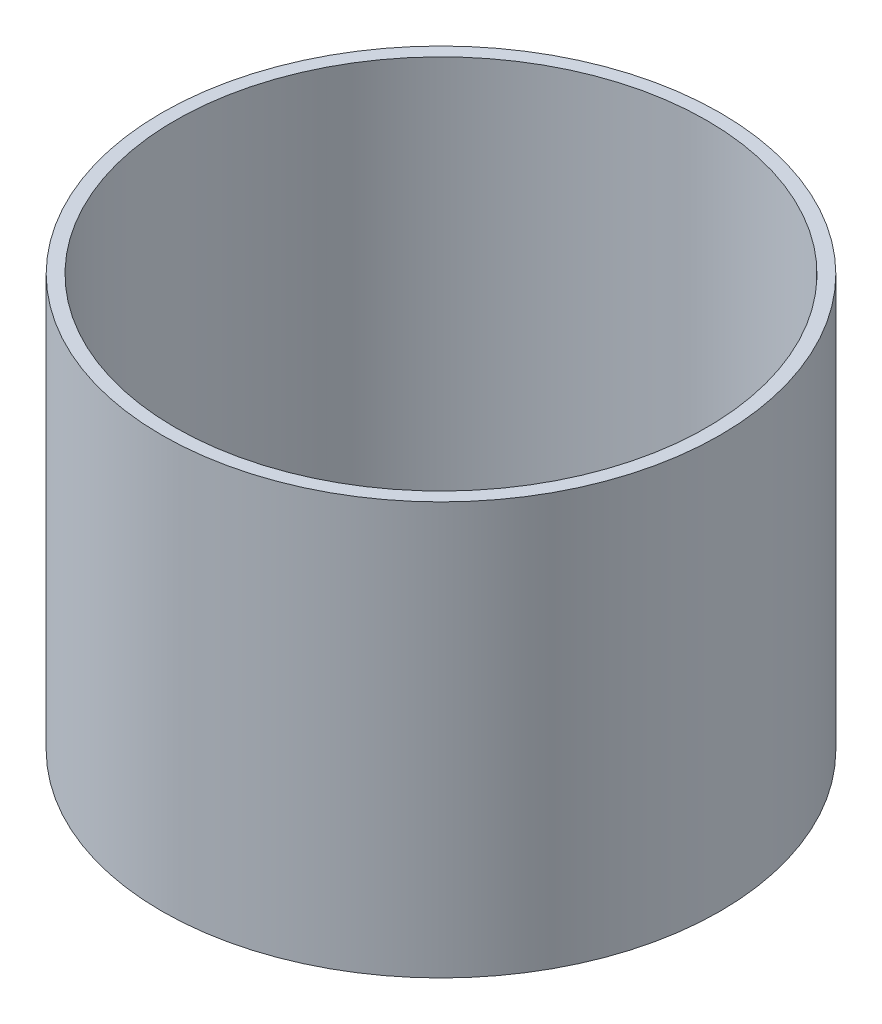
from build123d import *

# Parameters (mm, degrees)
SKETCH1_R           = 93.345
SKETCH1_R_2         = 88.9
BOSS_EXTRUDE1_DEPTH = 137.85088


with BuildPart() as part:
    # Sketch1 → Boss-Extrude1 (new body)
    with BuildSketch(Plane(origin=(0, 0, 0), x_dir=(1, 0, 0), z_dir=(0, 1, 0))):
        Circle(SKETCH1_R)
        Circle(SKETCH1_R_2, mode=Mode.SUBTRACT)
    extrude(amount=BOSS_EXTRUDE1_DEPTH)


solid = part.part
